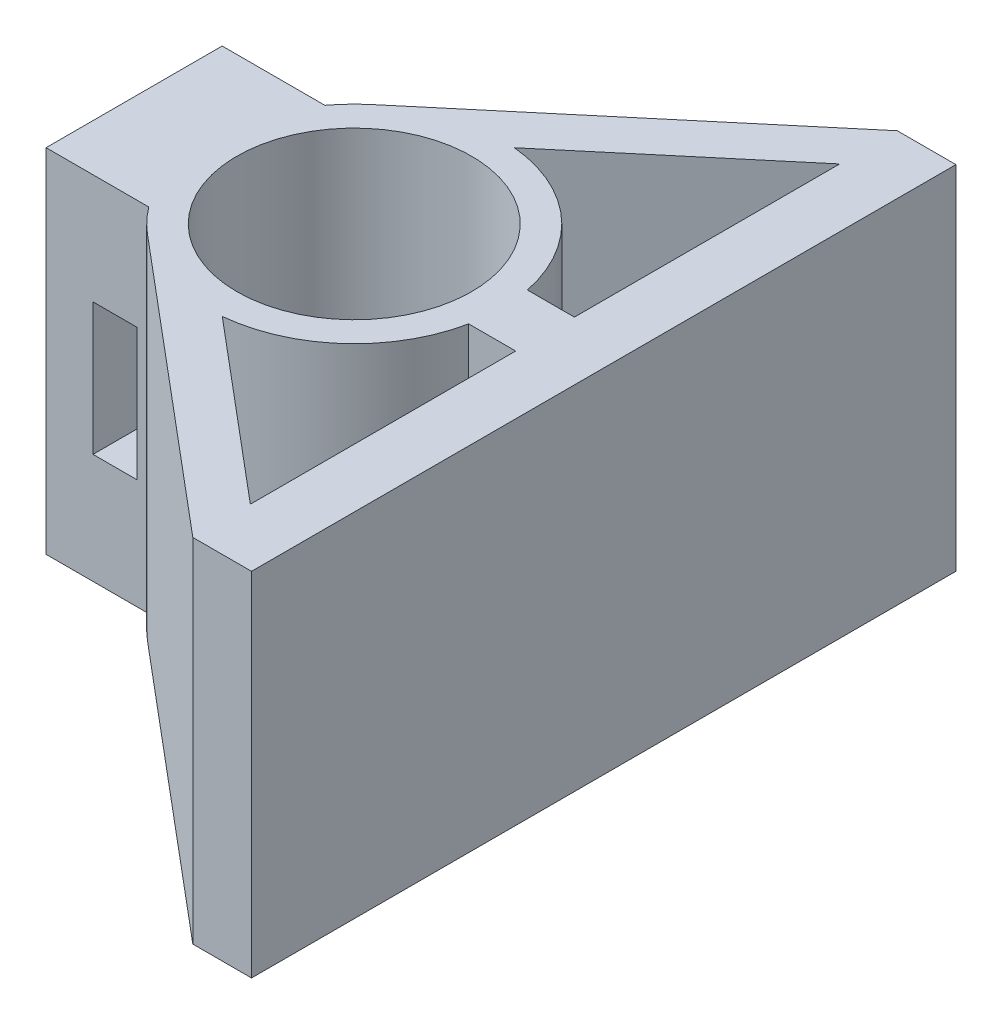
from build123d import *

# Parameters (mm, degrees)
BOSS_EXTRUDE1_DEPTH      = 6
BOSS_EXTRUDE1_DEPTH_BACK = 6
SKETCH1_R                = 4
SKETCH2_W                = 1.5
SKETCH2_H                = 4.5
CUT_EXTRUDE1_DEPTH       = 19.255136264


with BuildPart() as part:
    # Sketch1 → Boss-Extrude1 (new, two sides: drawn at the far end of the back side and taken through both)
    with BuildSketch(Plane(origin=(0, 0, 0), x_dir=(1, 0, 0), z_dir=(0, 1, 0)).offset(-BOSS_EXTRUDE1_DEPTH_BACK)):
        with BuildLine():
            Line((-4, 3), (-7.5, 3))
            Line((-7.5, 3), (-7.5, -3))
            Line((-7.5, -3), (-4, -3))
            ThreePointArc((-4, -3), (-3.632728032, -3.435591222), (-3.218284596, -3.826570823))
            Line((-3.218284596, -3.826570823), (6.5, -12))
            Line((6.5, -12), (8.5, -12))
            Line((8.5, -12), (8.5, -1.905552368))
            Line((8.5, -1.905552368), (8.5, 12))
            Line((8.5, 12), (6.5, 12))
            Line((6.5, 12), (-3.218284596, 3.826570823))
            ThreePointArc((-3.218284596, 3.826570823), (-3.632728032, 3.435591222), (-4, 3))
        make_face()
        Circle(SKETCH1_R, mode=Mode.SUBTRACT)
        with BuildLine():
            Line((4.898979486, 1), (6.5, 1))
            Line((6.5, 1), (6.5, 10.040020596))
            Line((6.5, 10.040020596), (0.479918949, 4.976914486))
            ThreePointArc((0.479918949, 4.976914486), (3.34471214, 3.716571095), (4.898979486, 1))
        make_face(mode=Mode.SUBTRACT)
        with BuildLine():
            Line((4.898979486, -1), (6.5, -1))
            Line((6.5, -1), (6.5, -10.040020596))
            Line((6.5, -10.040020596), (0.479918949, -4.976914486))
            ThreePointArc((0.479918949, -4.976914486), (3.34471214, -3.716571095), (4.898979486, -1))
        make_face(mode=Mode.SUBTRACT)
    extrude(amount=BOSS_EXTRUDE1_DEPTH + BOSS_EXTRUDE1_DEPTH_BACK)

    # Sketch2 → Cut-Extrude1 (cut, through all)
    with BuildSketch(Plane(origin=(0, 0, -3), x_dir=(-1, 0, 0), z_dir=(0, 0, -1))):
        with Locations((5.15, 0)):
            Rectangle(SKETCH2_W, SKETCH2_H)
    extrude(amount=-CUT_EXTRUDE1_DEPTH, mode=Mode.SUBTRACT)


solid = part.part
